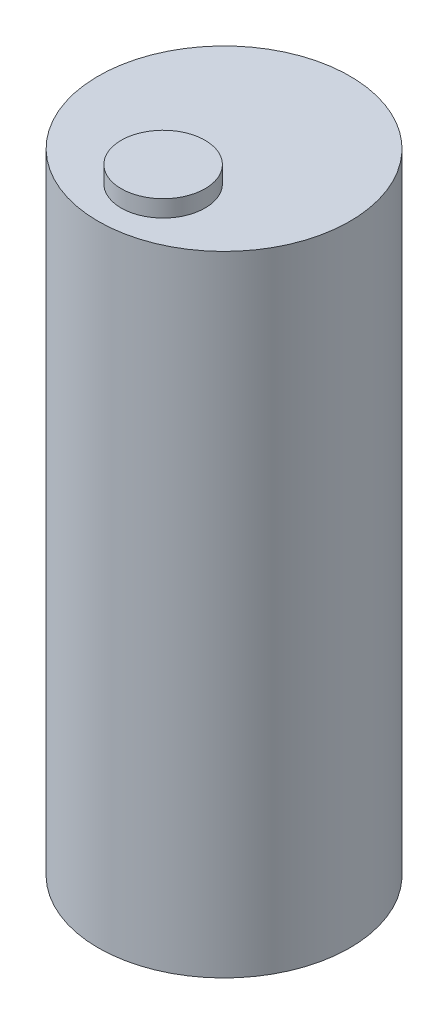
from build123d import *

# Parameters (mm, degrees)
SKETCH1_R           = 15
BOSS_EXTRUDE1_DEPTH = 75
SKETCH2_R           = 5
BOSS_EXTRUDE2_DEPTH = 2


with BuildPart() as part:
    # Sketch1 → Boss-Extrude1 (new body)
    with BuildSketch(Plane(origin=(0, 0, 0), x_dir=(1, 0, 0), z_dir=(0, 1, 0))):
        Circle(SKETCH1_R)
    extrude(amount=BOSS_EXTRUDE1_DEPTH)

    # Sketch2 → Boss-Extrude2 (add)
    with BuildSketch(Plane(origin=(0, 75, 0), x_dir=(1, 0, 0), z_dir=(0, 1, 0))):
        with Locations((0, -7.259763651)):
            Circle(SKETCH2_R)
    extrude(amount=BOSS_EXTRUDE2_DEPTH)


solid = part.part
